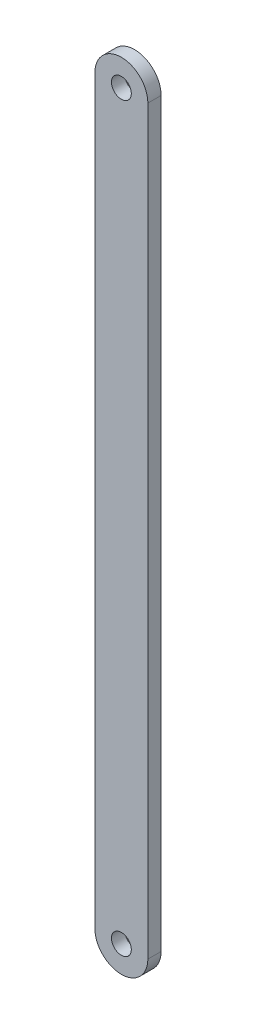
from build123d import *

# Parameters (mm, degrees)
SKETCH1_R           = 1.5
BOSS_EXTRUDE1_DEPTH = 2


with BuildPart() as part:
    # Sketch1 → Boss-Extrude1 (new body)
    with BuildSketch(Plane.XY):
        with BuildLine():
            Line((-4, 96.5), (-4, -15.5))
            ThreePointArc((-4, -15.5), (0, -19.5), (4, -15.5))
            Line((4, -15.5), (4, 96.5))
            ThreePointArc((4, 96.5), (0, 100.5), (-4, 96.5))
        make_face()
        with Locations((0, 96.5)):
            Circle(SKETCH1_R, mode=Mode.SUBTRACT)
        with Locations((0, -15.5)):
            Circle(SKETCH1_R, mode=Mode.SUBTRACT)
    extrude(amount=BOSS_EXTRUDE1_DEPTH)


solid = part.part
